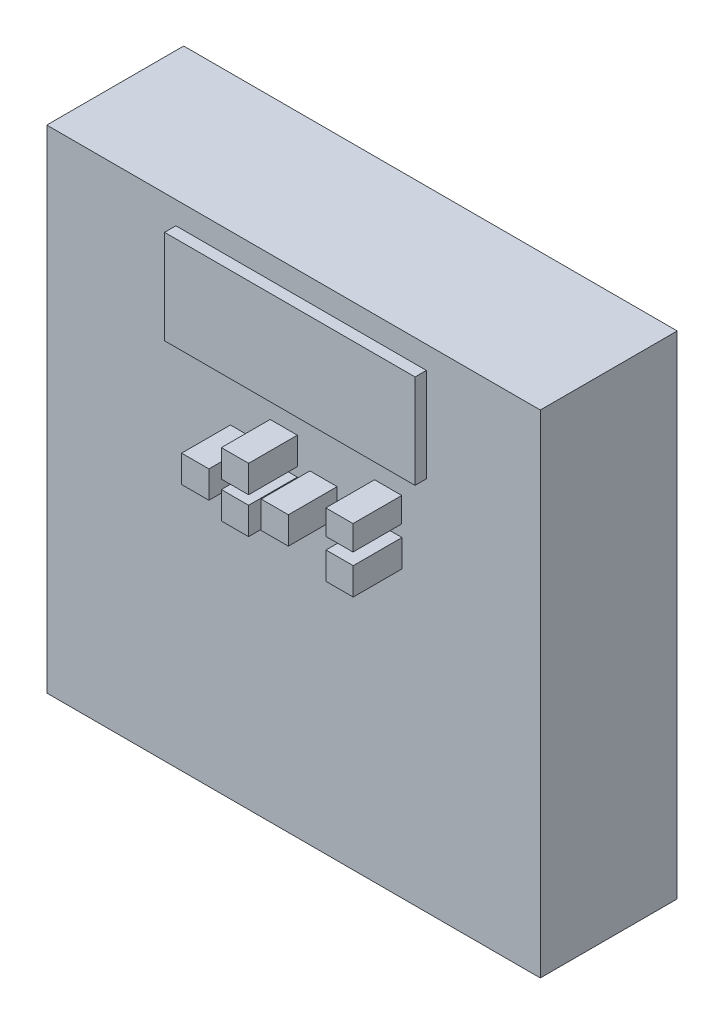
from build123d import *

# Parameters (mm, degrees)
SKETCH1_W           = 110.5916
SKETCH1_H           = 110.2233
BOSS_EXTRUDE1_DEPTH = 30.6832
SKETCH3_W           = 56.134
SKETCH3_H           = 21.0439
BOSS_EXTRUDE2_DEPTH = 2.54
SKETCH6_W           = 6.096
SKETCH6_H           = 6.1087
SKETCH6_W_2         = 6.1087
SKETCH6_H_2         = 6.096
SKETCH6_W_3         = 6.09854
SKETCH6_H_3         = 5.5245
BOSS_EXTRUDE3_DEPTH = 10.922


with BuildPart() as part:
    # Sketch1 → Boss-Extrude1 (new body)
    with BuildSketch(Plane.XY):
        Rectangle(SKETCH1_W, SKETCH1_H)
    extrude(amount=BOSS_EXTRUDE1_DEPTH)

    # Sketch3 → Boss-Extrude2 (add)
    with BuildSketch(Plane.XY.offset(30.6832)):
        with Locations((1.7018, 39.5097)):
            Rectangle(SKETCH3_W, SKETCH3_H)
    extrude(amount=BOSS_EXTRUDE2_DEPTH)

    # Sketch6 → Boss-Extrude3 (add)
    with BuildSketch(Plane.XY.offset(30.6832)):
        with Locations((-2.1971, 19.9517)):
            Rectangle(SKETCH6_W, SKETCH6_H)
        with Locations((-11.09345, 14.43355)):
            Rectangle(SKETCH6_W_2, SKETCH6_H_2)
        with Locations((6.71957, 14.43355)):
            Rectangle(SKETCH6_W_3, SKETCH6_H_2)
        with Locations((-2.1971, 11.81735)):
            Rectangle(SKETCH6_W, SKETCH6_H_2)
        with Locations((21.19884, 20.2438)):
            Rectangle(SKETCH6_W, SKETCH6_H_3)
        with Locations((21.2471, 11.81735)):
            Rectangle(SKETCH6_W, SKETCH6_H_2)
    extrude(amount=BOSS_EXTRUDE3_DEPTH)


solid = part.part
